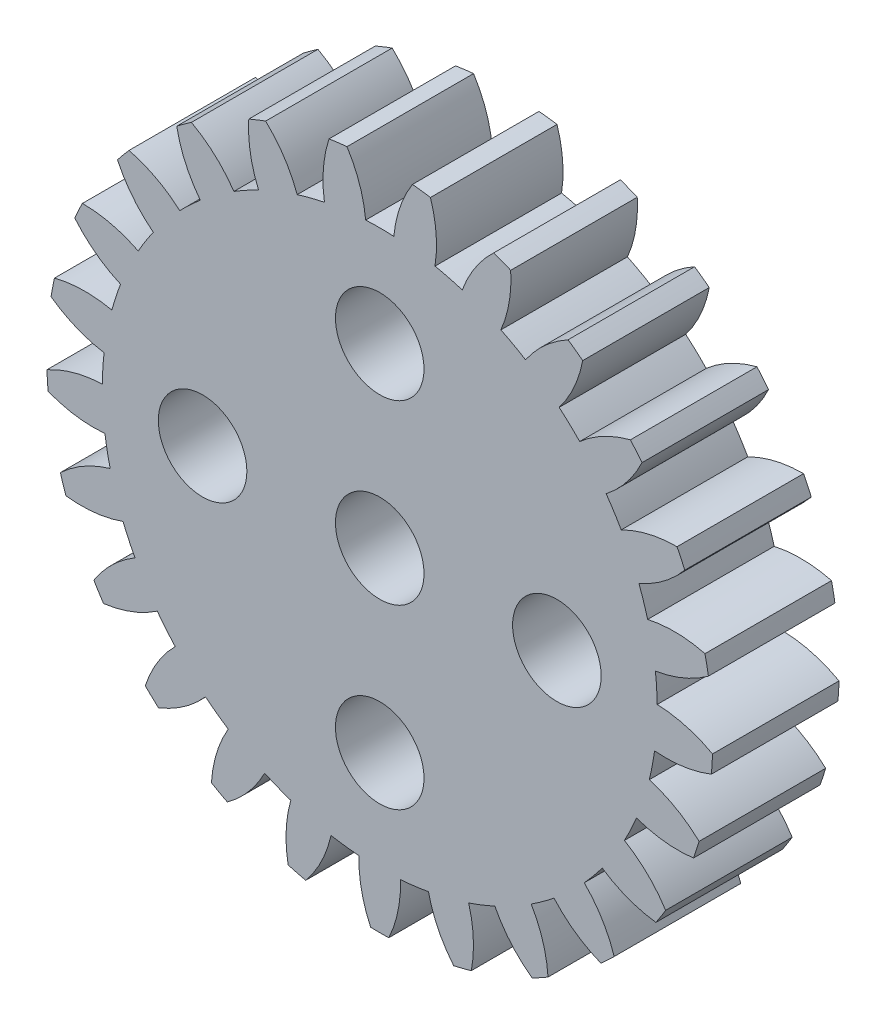
from build123d import *

# Parameters (mm, degrees)
SKETCH_1_R      = 1.75
EXTRUDE_1_DEPTH = 5


with BuildPart() as part:
    # 草图1 → 凸台-拉伸1 (new body)
    with BuildSketch(Plane.XY):
        with BuildLine():
            ThreePointArc((-33.626293755, 34.800259585), (-32.630644687, 34.242042741), (-31.532453571, 33.93075608))
            ThreePointArc((-31.532453571, 33.93075608), (-31.581480499, 33.376427799), (-31.602315919, 32.820325859))
            ThreePointArc((-31.602315919, 32.820325859), (-32.730862034, 32.64913363), (-33.788623234, 32.22010641))
            ThreePointArc((-33.788623234, 32.22010641), (-33.770984103, 31.861891352), (-33.743587892, 31.504290157))
            ThreePointArc((-33.743587892, 31.504290157), (-32.640396086, 31.211218576), (-31.499292819, 31.182820583))
            ThreePointArc((-31.499292819, 31.182820583), (-31.408923638, 30.633715043), (-31.290807547, 30.08990251))
            ThreePointArc((-31.290807547, 30.08990251), (-32.341324534, 29.643430594), (-33.25915949, 28.964827539))
            ThreePointArc((-33.25915949, 28.964827539), (-33.152990062, 28.622253139), (-33.037522753, 28.282699804))
            ThreePointArc((-33.037522753, 28.282699804), (-31.896105808, 28.273188251), (-30.783790105, 28.529463276))
            ThreePointArc((-30.783790105, 28.529463276), (-30.559703043, 28.020082798), (-30.310057108, 27.522729413))
            ThreePointArc((-30.310057108, 27.522729413), (-31.216537122, 26.829031282), (-31.936774888, 25.943491518))
            ThreePointArc((-31.936774888, 25.943491518), (-31.748746179, 25.638082986), (-31.552463008, 25.337912895))
            ThreePointArc((-31.552463008, 25.337912895), (-30.444540348, 25.612559017), (-29.430903095, 26.137404357))
            ThreePointArc((-29.430903095, 26.137404357), (-29.087178366, 25.69975519), (-28.72168876, 25.280111495))
            ThreePointArc((-28.72168876, 25.280111495), (-29.427174328, 24.382774754), (-29.904559716, 23.345940002))
            ThreePointArc((-29.904559716, 23.345940002), (-29.646486262, 23.096887279), (-29.381720421, 22.854961223))
            ThreePointArc((-29.381720421, 22.854961223), (-28.376906901, 23.396507993), (-27.525638655, 24.156945686))
            ThreePointArc((-27.525638655, 24.156945686), (-27.083873749, 23.818526936), (-26.625505528, 23.502960689))
            ThreePointArc((-26.625505528, 23.502960689), (-27.085668396, 22.458368305), (-27.290205527, 21.335386705))
            ThreePointArc((-27.290205527, 21.335386705), (-26.978303031, 21.158338689), (-26.661690733, 20.989857773))
            ThreePointArc((-26.661690733, 20.989857773), (-25.823122483, 21.764277816), (-25.187711558, 22.712526765))
            ThreePointArc((-25.187711558, 22.712526765), (-24.675664188, 22.494602526), (-24.153218313, 22.302941914))
            ThreePointArc((-24.153218313, 22.302941914), (-24.339144756, 21.17672947), (-24.25798181, 20.038162085))
            ThreePointArc((-24.25798181, 20.038162085), (-23.911848253, 19.944243355), (-23.563283412, 19.859793853))
            ThreePointArc((-23.563283412, 19.859793853), (-22.943650759, 20.81842751), (-22.564022361, 21.894905745))
            ThreePointArc((-22.564022361, 21.894905745), (-22.013866347, 21.811169), (-21.460170013, 21.755456764))
            ThreePointArc((-21.460170013, 21.755456764), (-21.36017759, 20.618388329), (-20.998414332, 19.535775537))
            ThreePointArc((-20.998414332, 19.535775537), (-20.63979856, 19.530887351), (-20.281182787, 19.535775537))
            ThreePointArc((-20.281182787, 19.535775537), (-19.919419529, 20.618388329), (-19.819427106, 21.755456764))
            ThreePointArc((-19.819427106, 21.755456764), (-19.265730773, 21.811169), (-18.715574758, 21.894905745))
            ThreePointArc((-18.715574758, 21.894905745), (-18.33594636, 20.81842751), (-17.716313707, 19.859793853))
            ThreePointArc((-17.716313707, 19.859793853), (-17.367748866, 19.944243355), (-17.021615309, 20.038162085))
            ThreePointArc((-17.021615309, 20.038162085), (-16.940452363, 21.17672947), (-17.126378806, 22.302941914))
            ThreePointArc((-17.126378806, 22.302941914), (-16.603932931, 22.494602526), (-16.091885561, 22.712526765))
            ThreePointArc((-16.091885561, 22.712526765), (-15.456474636, 21.764277816), (-14.617906386, 20.989857773))
            ThreePointArc((-14.617906386, 20.989857773), (-14.301294088, 21.158338689), (-13.989391592, 21.335386705))
            ThreePointArc((-13.989391592, 21.335386705), (-14.193928723, 22.458368305), (-14.654091591, 23.502960689))
            ThreePointArc((-14.654091591, 23.502960689), (-14.19572337, 23.818526936), (-13.753958464, 24.156945686))
            ThreePointArc((-13.753958464, 24.156945686), (-12.902690218, 23.396507993), (-11.897876698, 22.854961223))
            ThreePointArc((-11.897876698, 22.854961223), (-11.633110858, 23.096887279), (-11.375037403, 23.345940002))
            ThreePointArc((-11.375037403, 23.345940002), (-11.852422791, 24.382774754), (-12.557908359, 25.280111495))
            ThreePointArc((-12.557908359, 25.280111495), (-12.192418753, 25.69975519), (-11.848694025, 26.137404357))
            ThreePointArc((-11.848694025, 26.137404357), (-10.835056771, 25.612559017), (-9.727134111, 25.337912895))
            ThreePointArc((-9.727134111, 25.337912895), (-9.53085094, 25.638082986), (-9.342822231, 25.943491518))
            ThreePointArc((-9.342822231, 25.943491518), (-10.063059997, 26.829031282), (-10.969540011, 27.522729413))
            ThreePointArc((-10.969540011, 27.522729413), (-10.719894076, 28.020082798), (-10.495807014, 28.529463276))
            ThreePointArc((-10.495807014, 28.529463276), (-9.383491311, 28.273188251), (-8.242074366, 28.282699804))
            ThreePointArc((-8.242074366, 28.282699804), (-8.126607057, 28.622253139), (-8.020437629, 28.964827539))
            ThreePointArc((-8.020437629, 28.964827539), (-8.938272585, 29.643430594), (-9.988789572, 30.08990251))
            ThreePointArc((-9.988789572, 30.08990251), (-9.870673481, 30.633715043), (-9.7803043, 31.182820583))
            ThreePointArc((-9.7803043, 31.182820583), (-8.639201033, 31.211218576), (-7.536009227, 31.504290157))
            ThreePointArc((-7.536009227, 31.504290157), (-7.508613016, 31.861891352), (-7.490973885, 32.22010641))
            ThreePointArc((-7.490973885, 32.22010641), (-8.548735085, 32.64913363), (-9.6772812, 32.820325859))
            ThreePointArc((-9.6772812, 32.820325859), (-9.69811662, 33.376427799), (-9.747143548, 33.93075608))
            ThreePointArc((-9.747143548, 33.93075608), (-8.648952432, 34.242042741), (-7.653303364, 34.800259585))
            ThreePointArc((-7.653303364, 34.800259585), (-7.715699656, 35.153439241), (-7.787699154, 35.504786988))
            ThreePointArc((-7.787699154, 35.504786988), (-8.918923572, 35.657281016), (-10.054588111, 35.54243692))
            ThreePointArc((-10.054588111, 35.54243692), (-10.213065877, 36.075886337), (-10.398408371, 36.600606874))
            ThreePointArc((-10.398408371, 36.600606874), (-9.412132793, 37.175222917), (-8.586586755, 37.963510207))
            ThreePointArc((-8.586586755, 37.963510207), (-8.734854962, 38.290076748), (-8.891969094, 38.612480712))
            ThreePointArc((-8.891969094, 38.612480712), (-10.02557774, 38.478859787), (-11.097002724, 38.085195443))
            ThreePointArc((-11.097002724, 38.085195443), (-11.383165095, 38.562473748), (-11.693177405, 39.024616421))
            ThreePointArc((-11.693177405, 39.024616421), (-10.880788687, 39.826456606), (-10.277217773, 40.795283352))
            ThreePointArc((-10.277217773, 40.795283352), (-10.502041657, 41.074717401), (-10.734398366, 41.347919756))
            ThreePointArc((-10.734398366, 41.347919756), (-11.799162438, 40.936579772), (-12.739026295, 40.288830559))
            ThreePointArc((-12.739026295, 40.288830559), (-13.134892637, 40.679948601), (-13.550095549, 41.050475285))
            ThreePointArc((-13.550095549, 41.050475285), (-12.962639062, 42.029157045), (-12.618967852, 43.1176483))
            ThreePointArc((-12.618967852, 43.1176483), (-12.906220903, 43.332391988), (-13.199220361, 43.539226425))
            ThreePointArc((-13.199220361, 43.539226425), (-14.128236818, 42.876013386), (-14.877484445, 42.014879769))
            ThreePointArc((-14.877484445, 42.014879769), (-15.358181019, 42.295262162), (-15.852485808, 42.550891304))
            ThreePointArc((-15.852485808, 42.550891304), (-15.526873602, 43.644920465), (-15.464696223, 44.78468232))
            ThreePointArc((-15.464696223, 44.78468232), (-15.796329275, 44.921242511), (-16.131561249, 45.048712861))
            ThreePointArc((-16.131561249, 45.048712861), (-16.866456569, 44.175298882), (-17.378009983, 43.154889053))
            ThreePointArc((-17.378009983, 43.154889053), (-17.913332855, 43.306918341), (-18.455680533, 43.431587821))
            ThreePointArc((-18.455680533, 43.431587821), (-18.412372022, 44.572222507), (-18.635595307, 45.691639532))
            ThreePointArc((-18.635595307, 45.691639532), (-18.990770635, 45.741435648), (-19.347171267, 45.781532481))
            ThreePointArc((-19.347171267, 45.781532481), (-19.841769276, 44.752797373), (-20.083485693, 43.637227435))
            ThreePointArc((-20.083485693, 43.637227435), (-20.63979856, 43.651351059), (-21.196111426, 43.637227435))
            ThreePointArc((-21.196111426, 43.637227435), (-21.437827843, 44.752797373), (-21.932425852, 45.781532481))
            ThreePointArc((-21.932425852, 45.781532481), (-22.288826484, 45.741435648), (-22.644001812, 45.691639532))
            ThreePointArc((-22.644001812, 45.691639532), (-22.867225097, 44.572222507), (-22.823916586, 43.431587821))
            ThreePointArc((-22.823916586, 43.431587821), (-23.366264264, 43.306918341), (-23.901587137, 43.154889053))
            ThreePointArc((-23.901587137, 43.154889053), (-24.41314055, 44.175298882), (-25.14803587, 45.048712861))
            ThreePointArc((-25.14803587, 45.048712861), (-25.483267844, 44.921242511), (-25.814900896, 44.78468232))
            ThreePointArc((-25.814900896, 44.78468232), (-25.752723517, 43.644920465), (-25.427111311, 42.550891304))
            ThreePointArc((-25.427111311, 42.550891304), (-25.9214161, 42.295262162), (-26.402112674, 42.014879769))
            ThreePointArc((-26.402112674, 42.014879769), (-27.151360301, 42.876013386), (-28.080376758, 43.539226425))
            ThreePointArc((-28.080376758, 43.539226425), (-28.373376216, 43.332391988), (-28.660629267, 43.1176483))
            ThreePointArc((-28.660629267, 43.1176483), (-28.316958058, 42.029157045), (-27.72950157, 41.050475285))
            ThreePointArc((-27.72950157, 41.050475285), (-28.144704483, 40.679948601), (-28.540570824, 40.288830559))
            ThreePointArc((-28.540570824, 40.288830559), (-29.480434681, 40.936579772), (-30.545198753, 41.347919756))
            ThreePointArc((-30.545198753, 41.347919756), (-30.777555462, 41.074717401), (-31.002379346, 40.795283352))
            ThreePointArc((-31.002379346, 40.795283352), (-30.398808433, 39.826456606), (-29.586419714, 39.024616421))
            ThreePointArc((-29.586419714, 39.024616421), (-29.896432024, 38.562473748), (-30.182594395, 38.085195443))
            ThreePointArc((-30.182594395, 38.085195443), (-31.25401938, 38.478859787), (-32.387628025, 38.612480712))
            ThreePointArc((-32.387628025, 38.612480712), (-32.544742157, 38.290076748), (-32.693010364, 37.963510207))
            ThreePointArc((-32.693010364, 37.963510207), (-31.867464326, 37.175222917), (-30.881188748, 36.600606874))
            ThreePointArc((-30.881188748, 36.600606874), (-31.066531242, 36.075886337), (-31.225009008, 35.54243692))
            ThreePointArc((-31.225009008, 35.54243692), (-32.360673548, 35.657281016), (-33.491897965, 35.504786988))
            ThreePointArc((-33.491897965, 35.504786988), (-33.563897463, 35.153439241), (-33.626293755, 34.800259585))
        make_face()
        with Locations((-20.63979856, 39.688035521)):
            Circle(SKETCH_1_R, mode=Mode.SUBTRACT)
        with Locations((-13.63979856, 32.688035521)):
            Circle(SKETCH_1_R, mode=Mode.SUBTRACT)
        with Locations((-20.63979856, 25.688035521)):
            Circle(SKETCH_1_R, mode=Mode.SUBTRACT)
        with Locations((-27.63979856, 32.688035521)):
            Circle(SKETCH_1_R, mode=Mode.SUBTRACT)
        with Locations((-20.63979856, 32.688035521)):
            Circle(SKETCH_1_R, mode=Mode.SUBTRACT)
    extrude(amount=EXTRUDE_1_DEPTH)


solid = part.part
